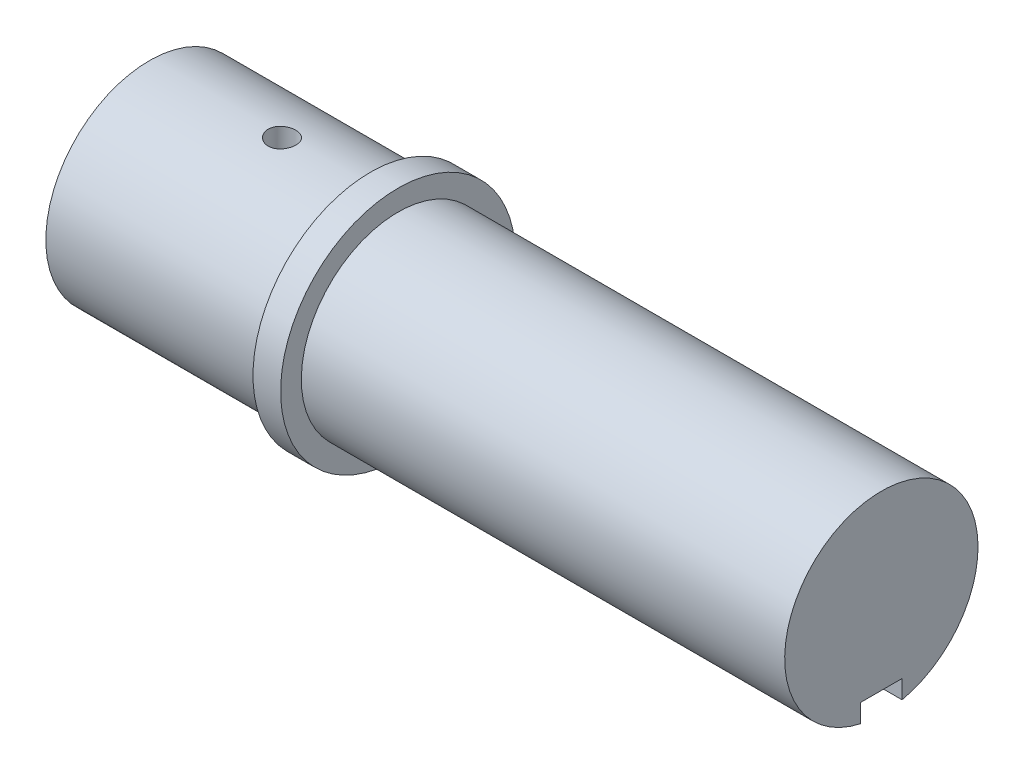
from build123d import *

# Parameters (mm, degrees)
SKETCH1_R           = 7.5
BOSS_EXTRUDE1_DEPTH = 16
SKETCH2_R           = 8.5
BOSS_EXTRUDE2_DEPTH = 2
SKETCH3_R           = 7
BOSS_EXTRUDE3_DEPTH = 35
SKETCH4_R           = 4
CUT_EXTRUDE1_DEPTH  = 20.5
SKETCH6_W           = 3
SKETCH6_H           = 1.5
CUT_EXTRUDE2_DEPTH  = 20.5
CUT_EXTRUDE3_REACH  = 18
SKETCH7_R           = 1
SKETCH8_W           = 3
SKETCH8_H           = 3
CUT_EXTRUDE5_DEPTH  = 33


with BuildPart() as part:
    # Sketch1 → Boss-Extrude1 (new body)
    with BuildSketch(Plane(origin=(0, 0, 0), x_dir=(0, 0, -1), z_dir=(1, 0, 0))):
        Circle(SKETCH1_R)
    extrude(amount=BOSS_EXTRUDE1_DEPTH)

    # Sketch2 → Boss-Extrude2 (add)
    with BuildSketch(Plane(origin=(16, 0, 0), x_dir=(0, 0, -1), z_dir=(1, 0, 0))):
        Circle(SKETCH2_R)
    extrude(amount=BOSS_EXTRUDE2_DEPTH)

    # Sketch3 → Boss-Extrude3 (add)
    with BuildSketch(Plane(origin=(18, 0, 0), x_dir=(0, 0, -1), z_dir=(1, 0, 0))):
        Circle(SKETCH3_R)
    extrude(amount=BOSS_EXTRUDE3_DEPTH)

    # Sketch4 → Cut-Extrude1 (cut)
    with BuildSketch(Plane.ZY):
        Circle(SKETCH4_R)
    extrude(amount=-CUT_EXTRUDE1_DEPTH, mode=Mode.SUBTRACT)

    # Sketch6 → Cut-Extrude2 (cut)
    with BuildSketch(Plane.ZY):
        with Locations((0, 4)):
            Rectangle(SKETCH6_W, SKETCH6_H)
    extrude(amount=-CUT_EXTRUDE2_DEPTH, mode=Mode.SUBTRACT)

    # Sketch7 → Cut-Extrude3 (cut, up to next)
    with BuildSketch(Plane(origin=(0, 7.5, 0), x_dir=(1, 0, 0), z_dir=(0, 1, 0)), mode=Mode.PRIVATE) as cut_extrude3_sk1:
        with Locations((9.6, 0)):
            Circle(SKETCH7_R)
    cut_extrude3_tool1 = extrude(cut_extrude3_sk1.sketch, amount=-CUT_EXTRUDE3_REACH, mode=Mode.PRIVATE) & part.part
    add(cut_extrude3_tool1.solids().sort_by_distance((9.6, 7.5, 0))[0], mode=Mode.SUBTRACT)

    # Sketch8 → Cut-Extrude5 (cut)
    with BuildSketch(Plane(origin=(53, 0, 0), x_dir=(0, 0, -1), z_dir=(1, 0, 0))):
        with Locations((0, -7)):
            Rectangle(SKETCH8_W, SKETCH8_H)
    extrude(amount=-CUT_EXTRUDE5_DEPTH, mode=Mode.SUBTRACT)


solid = part.part
